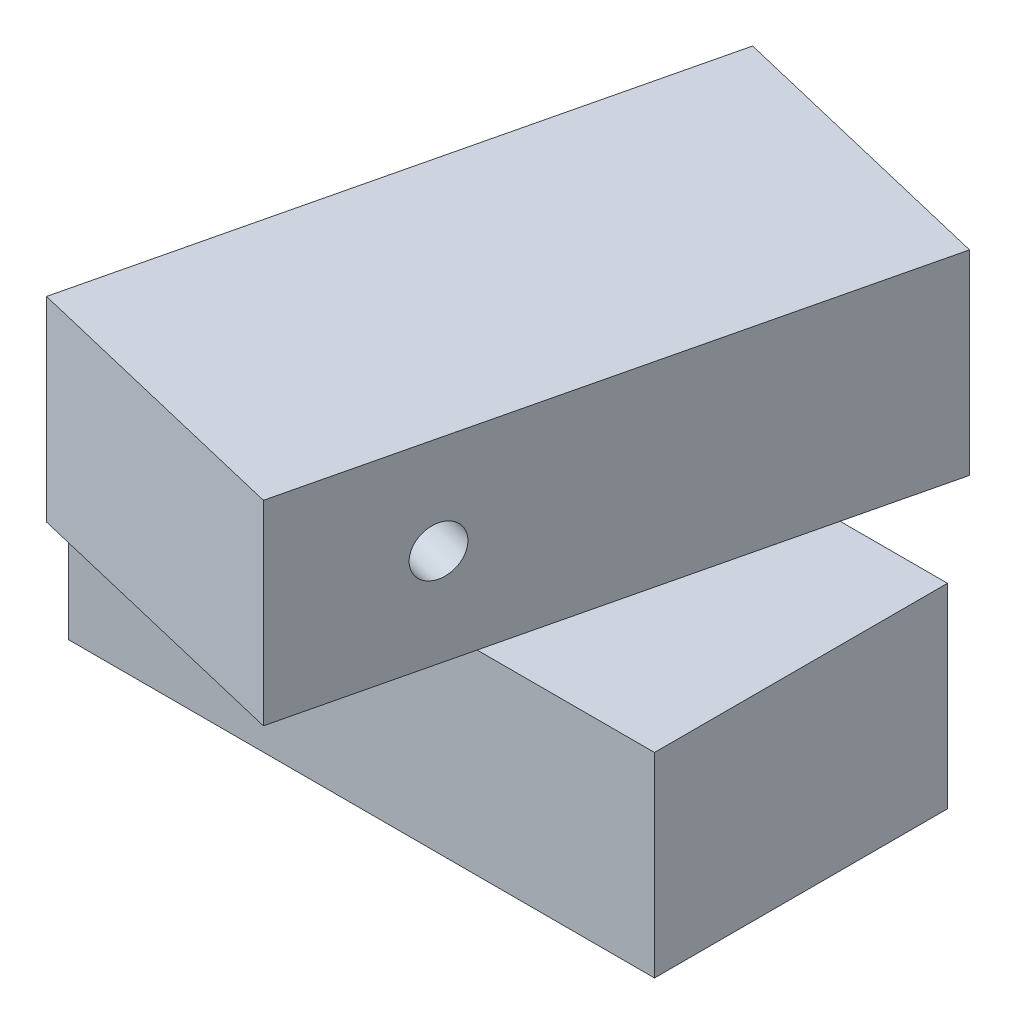
from build123d import *

# Parameters (mm, degrees)
SKETCH1_W           = 120
SKETCH1_H           = 40
BOSS_EXTRUDE1_DEPTH = 30
BOSS_EXTRUDE2_DEPTH = 40
SKETCH3_R           = 5
CUT_EXTRUDE1_DEPTH  = 104.536516906


with BuildPart() as part:
    # Sketch1 → Boss-Extrude1 (new body, symmetric)
    with BuildSketch(Plane.XY):
        Rectangle(SKETCH1_W, SKETCH1_H)
    extrude(amount=BOSS_EXTRUDE1_DEPTH, both=True)

    # Sketch2 → Boss-Extrude2 (add)
    with BuildSketch(Plane(origin=(0, 20, 0), x_dir=(1, 0, 0), z_dir=(0, 1, 0))):
        Polygon((-15.23855654, 65.328297043), (-43.119503711, -51.387823458), (15.23855654, -65.328297043), (43.119503711, 51.387823458), align=None)
    extrude(amount=BOSS_EXTRUDE2_DEPTH)

    # Sketch3 → Cut-Extrude1 (cut, through all)
    with BuildSketch(Plane(origin=(29.179030125, 50, 6.970236793), x_dir=(0.053982445, -0.972634338, -0.225983055), z_dir=(0.972634338, 0, 0.232341226))):
        with Locations((2.700680063, -31.734470672)):
            Circle(SKETCH3_R)
    extrude(amount=-CUT_EXTRUDE1_DEPTH, mode=Mode.SUBTRACT)


solid = part.part
